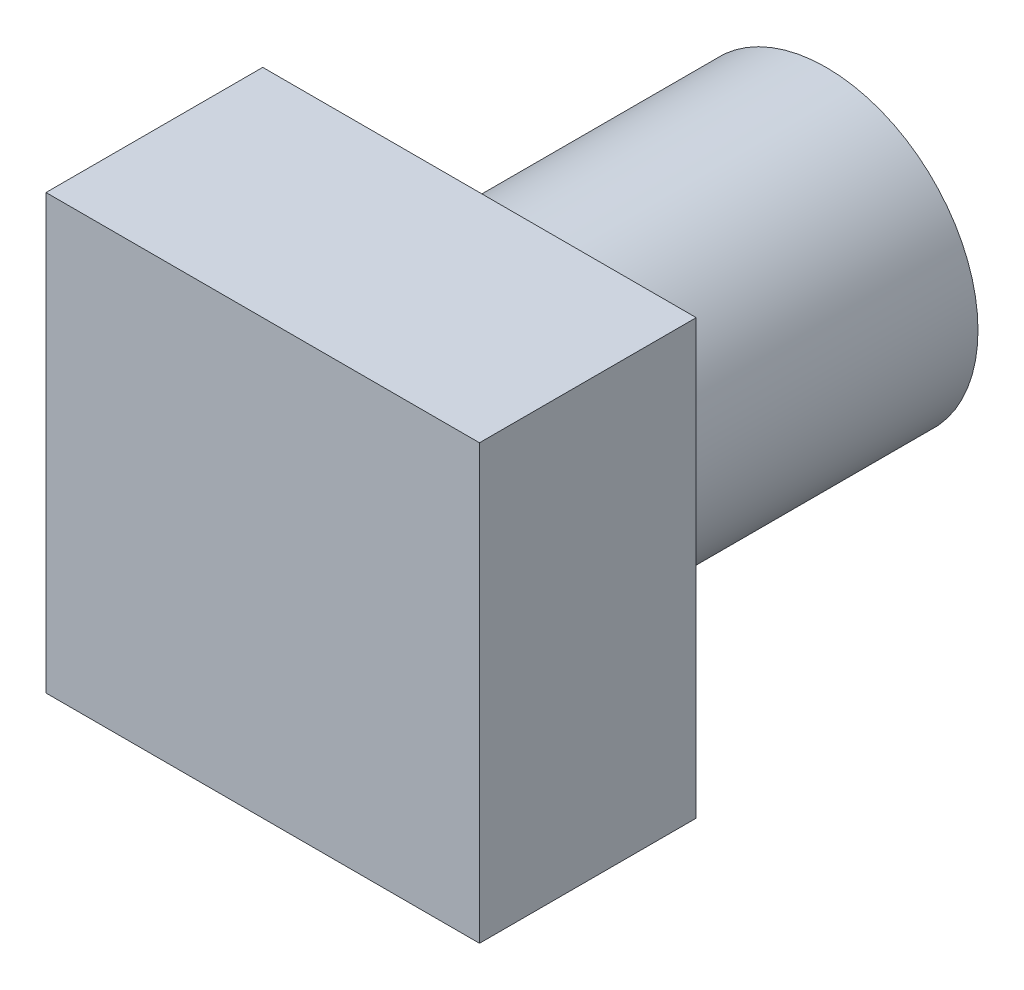
from build123d import *

# Parameters (mm, degrees)
SKETCH2_W           = 10
SKETCH2_H           = 10
BOSS_EXTRUDE1_DEPTH = 5
SKETCH4_W           = 15
SKETCH4_H           = 27.94
BOSS_EXTRUDE4_DEPTH = 4
SKETCH5_W           = 2.25448465
SKETCH5_H           = 27.94
BOSS_EXTRUDE5_DEPTH = 4
SKETCH6_R           = 1.5
CUT_EXTRUDE1_DEPTH  = 40
SKETCH7_R           = 3.5
BOSS_EXTRUDE6_DEPTH = 8
SKETCH8_W           = 15
SKETCH8_H           = 27.94
CUT_EXTRUDE2_DEPTH  = 8


with BuildPart() as part:
    # Sketch2 → Boss-Extrude1 (new body)
    with BuildSketch(Plane.XY):
        with Locations((5, 5)):
            Rectangle(SKETCH2_W, SKETCH2_H)
    extrude(amount=BOSS_EXTRUDE1_DEPTH)

    # Sketch4 → Boss-Extrude4 (add)
    with BuildSketch(Plane.XY.offset(5)):
        with Locations((7.5, 5)):
            Rectangle(SKETCH4_W, SKETCH4_H)
    extrude(amount=BOSS_EXTRUDE4_DEPTH)

    # Sketch5 → Boss-Extrude5 (add)
    with BuildSketch(Plane.XY.offset(9)):
        with Locations((13.872757675, 5)):
            Rectangle(SKETCH5_W, SKETCH5_H)
    extrude(amount=BOSS_EXTRUDE5_DEPTH)

    # Sketch6 → Cut-Extrude1 (cut)
    with BuildSketch(Plane.ZY.offset(-12.74551535)):
        with Locations((11.286, 16.64426)):
            Circle(SKETCH6_R)
        with Locations((11.286, -6.645)):
            Circle(SKETCH6_R)
    extrude(amount=-CUT_EXTRUDE1_DEPTH, mode=Mode.SUBTRACT)

    # Sketch7 → Boss-Extrude6 (add)
    with BuildSketch(Plane(origin=(0, 0, 0), x_dir=(-1, 0, 0), z_dir=(0, 0, -1))):
        with Locations((-5, 5)):
            Circle(SKETCH7_R)
    extrude(amount=BOSS_EXTRUDE6_DEPTH)

    # Sketch8 → Cut-Extrude2 (cut)
    with BuildSketch(Plane.XY.offset(13)):
        with Locations((7.5, 5)):
            Rectangle(SKETCH8_W, SKETCH8_H)
    extrude(amount=-CUT_EXTRUDE2_DEPTH, mode=Mode.SUBTRACT)


solid = part.part
